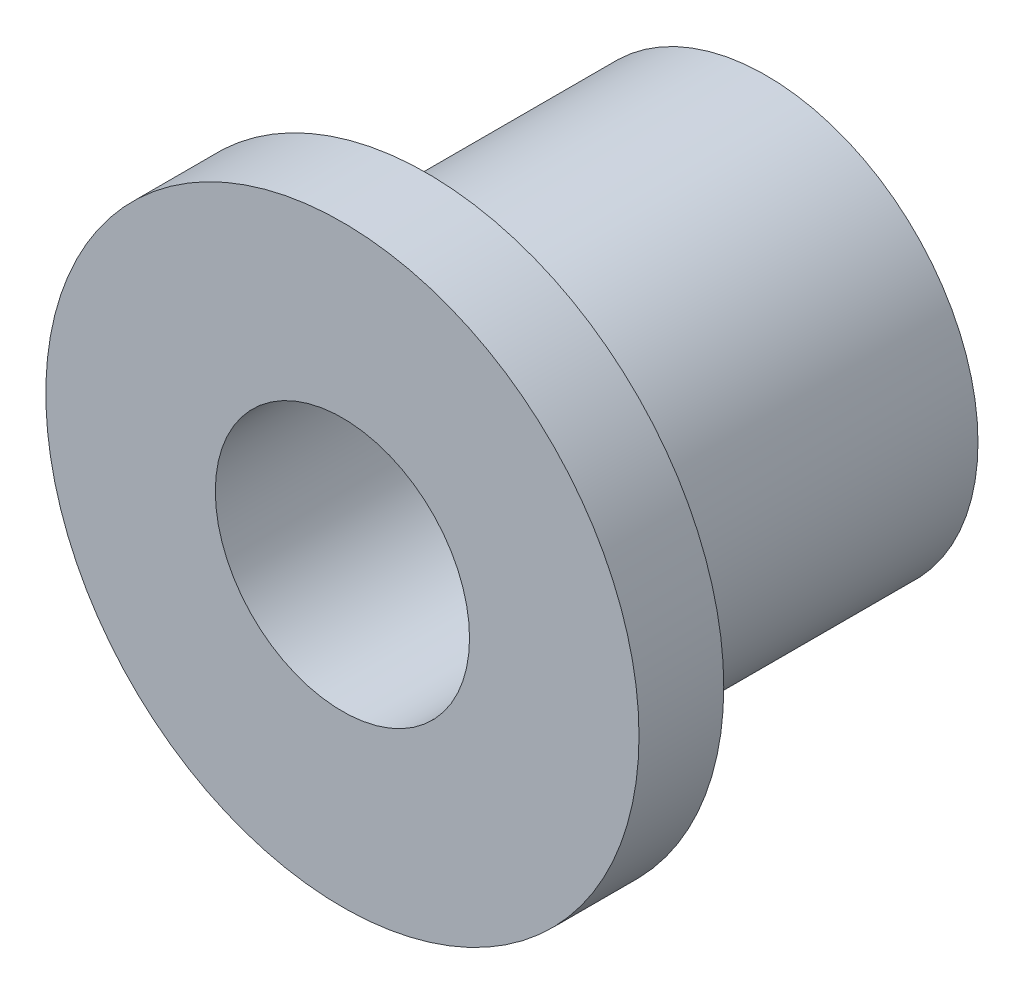
from build123d import *

# Parameters (mm, degrees)
SKETCH1_R           = 3.96875
SKETCH1_R_2         = 2.38125
BOSS_EXTRUDE1_DEPTH = 6.35
SKETCH2_R           = 5.55625
SKETCH2_R_2         = 2.38125
BOSS_EXTRUDE2_DEPTH = 1.5875


with BuildPart() as part:
    # Sketch1 → Boss-Extrude1 (new body)
    with BuildSketch(Plane.XY):
        Circle(SKETCH1_R)
        Circle(SKETCH1_R_2, mode=Mode.SUBTRACT)
    extrude(amount=BOSS_EXTRUDE1_DEPTH)

    # Sketch2 → Boss-Extrude2 (add)
    with BuildSketch(Plane.XY.offset(6.35)):
        Circle(SKETCH2_R)
        Circle(SKETCH2_R_2, mode=Mode.SUBTRACT)
    extrude(amount=BOSS_EXTRUDE2_DEPTH)


solid = part.part
